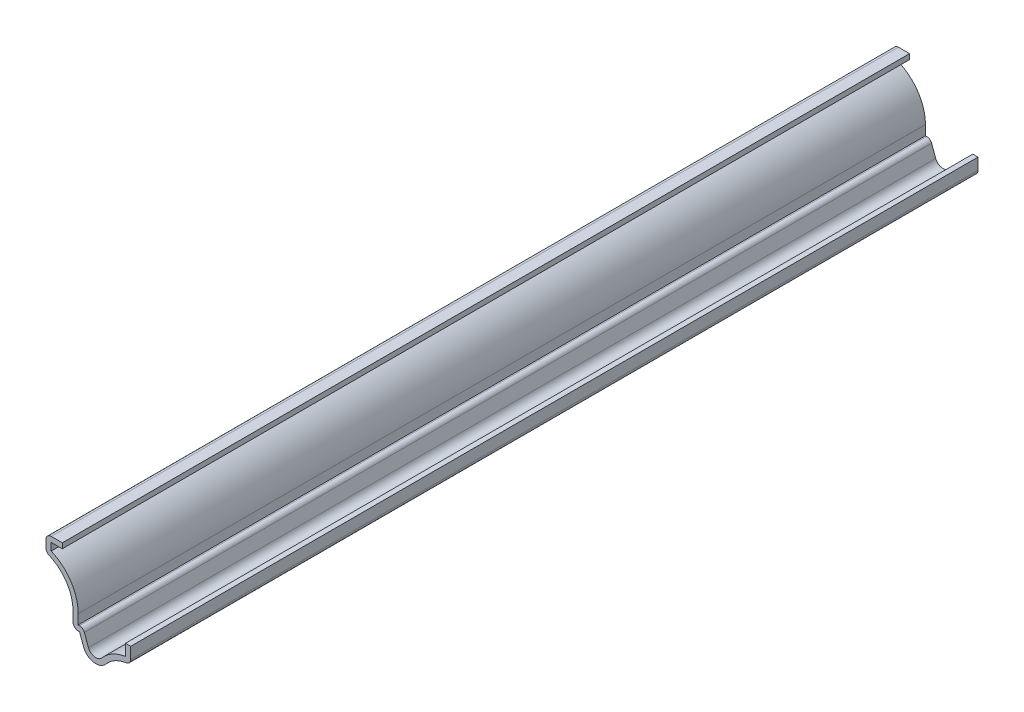
from build123d import *

# Parameters (mm, degrees)
EXTRUDE_THIN1_DEPTH = 206.375
FILLET1_R           = 1.27


with BuildPart() as part:
    # Sketch1 → Extrude-Thin1 (new body)
    with BuildSketch(Plane.XY):
        with BuildLine():
            Line((0, 7.9375), (0, 3.96875))
            ThreePointArc((0, 3.96875), (-3.354205948, 3.225220302), (-6.080014609, 1.133928571))
            ThreePointArc((-6.080014609, 1.133928571), (-9.057226525, 0.047161235), (-11.491167025, 2.077133569))
            Line((-11.491167025, 2.077133569), (-12.480770453, 4.7625))
            Line((-12.480770453, 4.7625), (-14.068270453, 4.7625))
            Line((-14.068270453, 4.7625), (-14.068270453, 8.407719714))
            ThreePointArc((-14.068270453, 8.407719714), (-15.883557794, 14.00110471), (-20.6375, 17.4625))
            Line((-20.6375, 17.4625), (-20.6375, 21.43125))
            Line((-20.6375, 21.43125), (-16.66875, 21.43125))
            Line((-16.66875, 21.43125), (-16.66875, 20.16125))
            Line((-16.66875, 20.16125), (-19.3675, 20.16125))
            Line((-19.3675, 20.16125), (-19.3675, 18.341243212))
            ThreePointArc((-19.3675, 18.341243212), (-14.589126489, 14.362332756), (-12.798270453, 8.407719714))
            Line((-12.798270453, 8.407719714), (-12.798270453, 6.0325))
            Line((-12.798270453, 6.0325), (-11.595295513, 6.0325))
            Line((-11.595295513, 6.0325), (-10.299508396, 2.516280141))
            ThreePointArc((-10.299508396, 2.516280141), (-8.839144096, 1.298296741), (-7.052816947, 1.950357143))
            ThreePointArc((-7.052816947, 1.950357143), (-4.458468146, 4.08731095), (-1.27, 5.150743201))
            Line((-1.27, 5.150743201), (-1.27, 7.9375))
            Line((-1.27, 7.9375), (0, 7.9375))
        make_face()
    extrude(amount=-EXTRUDE_THIN1_DEPTH)

    # Fillet1
    fillet1_edges = [part.edges().sort_by_distance(p)[0] for p in [
        (-11.595295513, 6.0325, -103.1875),
        (0, 3.96875, -103.1875),
        (-14.068270453, 4.7625, -103.1875),
        (-20.6375, 17.4625, -103.1875),
        (-20.6375, 21.43125, -103.1875),
    ]]
    fillet(fillet1_edges, radius=FILLET1_R)


solid = part.part
